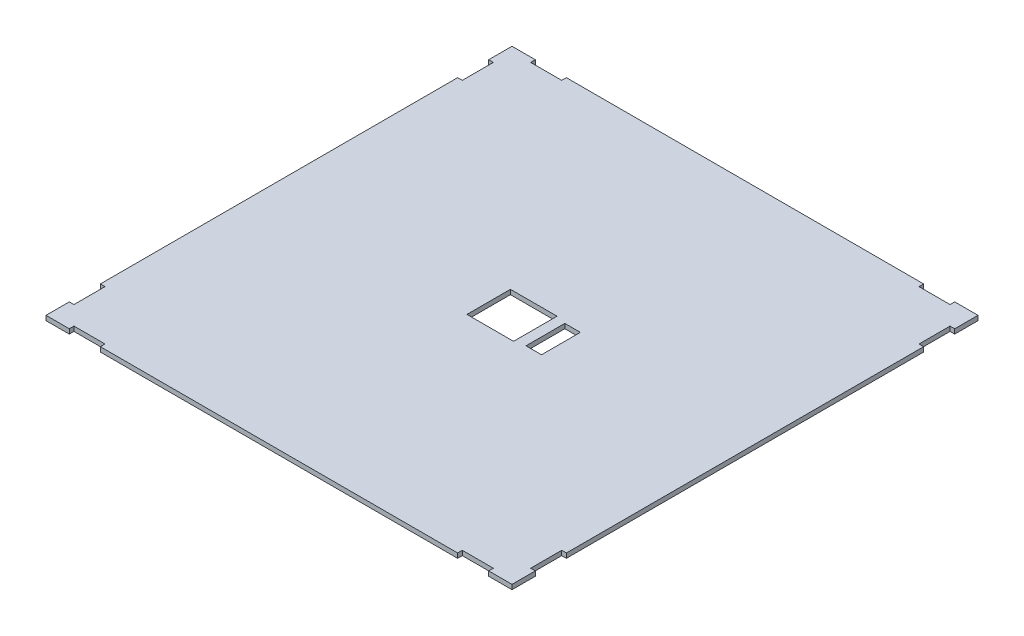
from build123d import *

# Parameters (mm, degrees)
CROQUIS1_W              = 30
CROQUIS1_H              = 28
CROQUIS1_W_2            = 10
CROQUIS1_H_2            = 25
SALIENTE_EXTRUIR2_DEPTH = 3


with BuildPart() as part:
    # Croquis1 → Saliente-Extruir2 (new body)
    with BuildSketch(Plane(origin=(0, 0, 0), x_dir=(1, 0, 0), z_dir=(0, 1, 0))):
        Polygon((0, 0), (15, 0), (15, 3), (35, 3), (35, 0), (265, 0), (265, 3), (285, 3), (285, 0), (300, 0), (300, 15), (297, 15), (297, 35), (300, 35), (300, 265), (297, 265), (297, 285), (300, 285), (300, 300), (285, 300), (285, 297), (265, 297), (265, 300), (35, 300), (35, 297), (15, 297), (15, 300), (0, 300), (0, 285), (3, 285), (3, 265), (0, 265), (0, 35), (3, 35), (3, 15), (0, 15), align=None)
        with Locations((150, 150)):
            Rectangle(CROQUIS1_W, CROQUIS1_H, mode=Mode.SUBTRACT)
        with Locations((176.5, 150)):
            Rectangle(CROQUIS1_W_2, CROQUIS1_H_2, mode=Mode.SUBTRACT)
    extrude(amount=SALIENTE_EXTRUIR2_DEPTH)


solid = part.part
